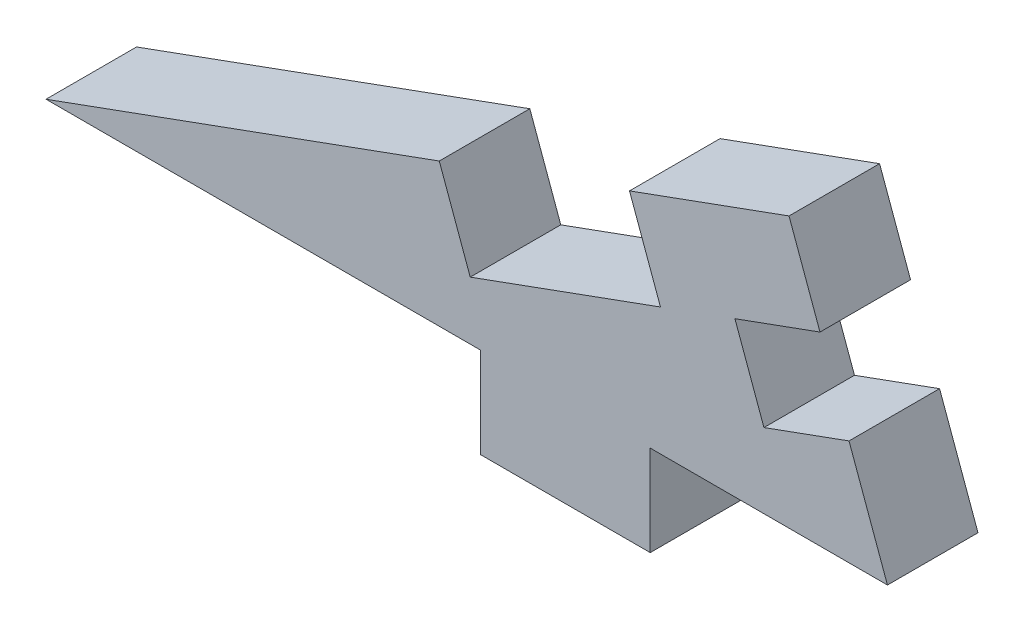
from build123d import *

# Parameters (mm, degrees)
BOSS_EXTRUDE1_DEPTH = 5.08
BOSS_EXTRUDE2_DEPTH = 5.08
CUT_EXTRUDE1_DEPTH  = 6.08


with BuildPart() as part:
    # Sketch1 → Boss-Extrude1 (new body)
    with BuildSketch(Plane.XY):
        Polygon((19.624427787, 7.142707579), (8.950572213, 3.257741865), (7.213109885, 8.031380379), (-1.737462328, 4.773638514), (0, 0), (9.525, 0), (9.525, -5.08), (19.05, -5.08), (19.05, 0), (28.575, 0), (28.575, 10.400449444), (26.837537672, 15.174087958), (17.886965459, 11.916346093), align=None)
    extrude(amount=BOSS_EXTRUDE1_DEPTH)

    # Sketch2 → Boss-Extrude2 (add)
    with BuildSketch(Plane.XY.offset(5.08)):
        Polygon((28.575, 10.400449444), (28.575, 0), (32.360454021, 0), align=None)
        Polygon((0, 0), (-14.852926353, 0), (-1.737462328, 4.773638514), align=None)
    extrude(amount=-BOSS_EXTRUDE2_DEPTH)

    # Sketch3 → Cut-Extrude1 (cut, through all)
    with BuildSketch(Plane.XY.offset(5.08)):
        Polygon((28.575, 10.400449444), (30.203870933, 5.925163338), (25.430232419, 4.18770101), (23.801361486, 8.662987116), align=None)
    extrude(amount=-CUT_EXTRUDE1_DEPTH, mode=Mode.SUBTRACT)


solid = part.part
